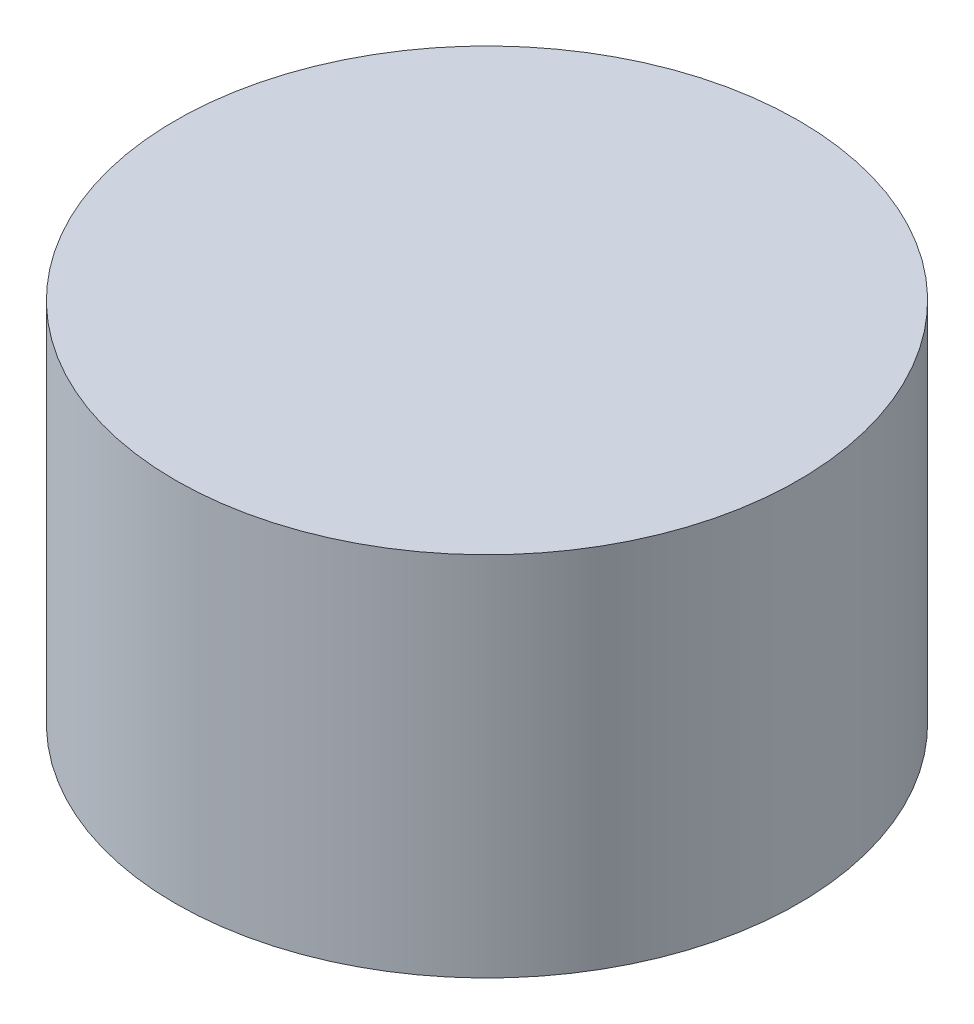
from build123d import *

# Parameters (mm, degrees)
SKETCH1_R           = 8.5
BOSS_EXTRUDE1_DEPTH = 10


with BuildPart() as part:
    # Sketch1 → Boss-Extrude1 (new body)
    with BuildSketch(Plane(origin=(0, 0, 0), x_dir=(1, 0, 0), z_dir=(0, 1, 0))):
        with Locations((-2.573020929, 1.574282542)):
            Circle(SKETCH1_R)
    extrude(amount=BOSS_EXTRUDE1_DEPTH)


solid = part.part
